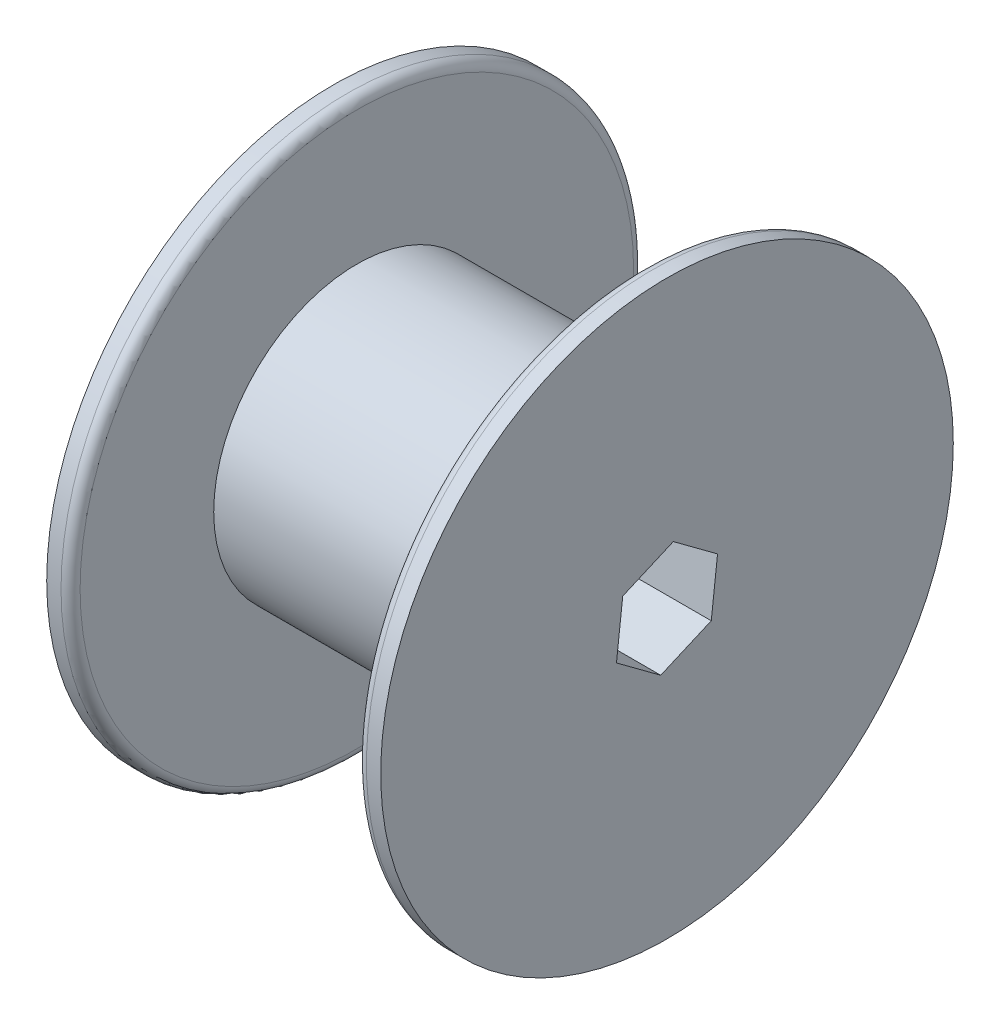
from build123d import *

# Parameters (mm, degrees)
SKETCH1_R           = 19.05
BOSS_EXTRUDE1_DEPTH = 38.1
SKETCH2_R           = 38.1
BOSS_EXTRUDE2_DEPTH = 3.175
SKETCH3_R           = 38.1
BOSS_EXTRUDE3_DEPTH = 3.175
SKETCH4_R           = 6.35
CUT_EXTRUDE1_DEPTH  = 45.45
FILLET1_R           = 1.27
CUT_EXTRUDE2_DEPTH  = 45.45


with BuildPart() as part:
    # Sketch1 → Boss-Extrude1 (new body)
    with BuildSketch(Plane(origin=(0, 0, 0), x_dir=(0, 0, -1), z_dir=(1, 0, 0))):
        Circle(SKETCH1_R)
    extrude(amount=BOSS_EXTRUDE1_DEPTH)

    # Sketch2 → Boss-Extrude2 (add)
    with BuildSketch(Plane.ZY):
        Circle(SKETCH2_R)
    extrude(amount=BOSS_EXTRUDE2_DEPTH)

    # Sketch3 → Boss-Extrude3 (add)
    with BuildSketch(Plane(origin=(38.1, 0, 0), x_dir=(0, 0, -1), z_dir=(1, 0, 0))):
        Circle(SKETCH3_R)
    extrude(amount=BOSS_EXTRUDE3_DEPTH)

    # Sketch4 → Cut-Extrude1 (cut, through all)
    with BuildSketch(Plane.ZY.offset(3.175)):
        Circle(SKETCH4_R)
    extrude(amount=-CUT_EXTRUDE1_DEPTH, mode=Mode.SUBTRACT)

    # Fillet1
    fillet1_edges = [part.edges().sort_by_distance(p)[0] for p in [
        (0, 0, -38.1),
        (38.1, 0, 38.1),
    ]]
    fillet(fillet1_edges, radius=FILLET1_R)

    # Sketch5 → Cut-Extrude2 (cut, through all)
    with BuildSketch(Plane.ZY.offset(3.175)):
        Polygon((-5.890350999, -4.366588879), (0.836401397, -7.284488042), (6.726752397, -2.917899163), (5.890350999, 4.366588879), (-0.836401397, 7.284488042), (-6.726752397, 2.917899163), align=None)
    extrude(amount=-CUT_EXTRUDE2_DEPTH, mode=Mode.SUBTRACT)


solid = part.part
